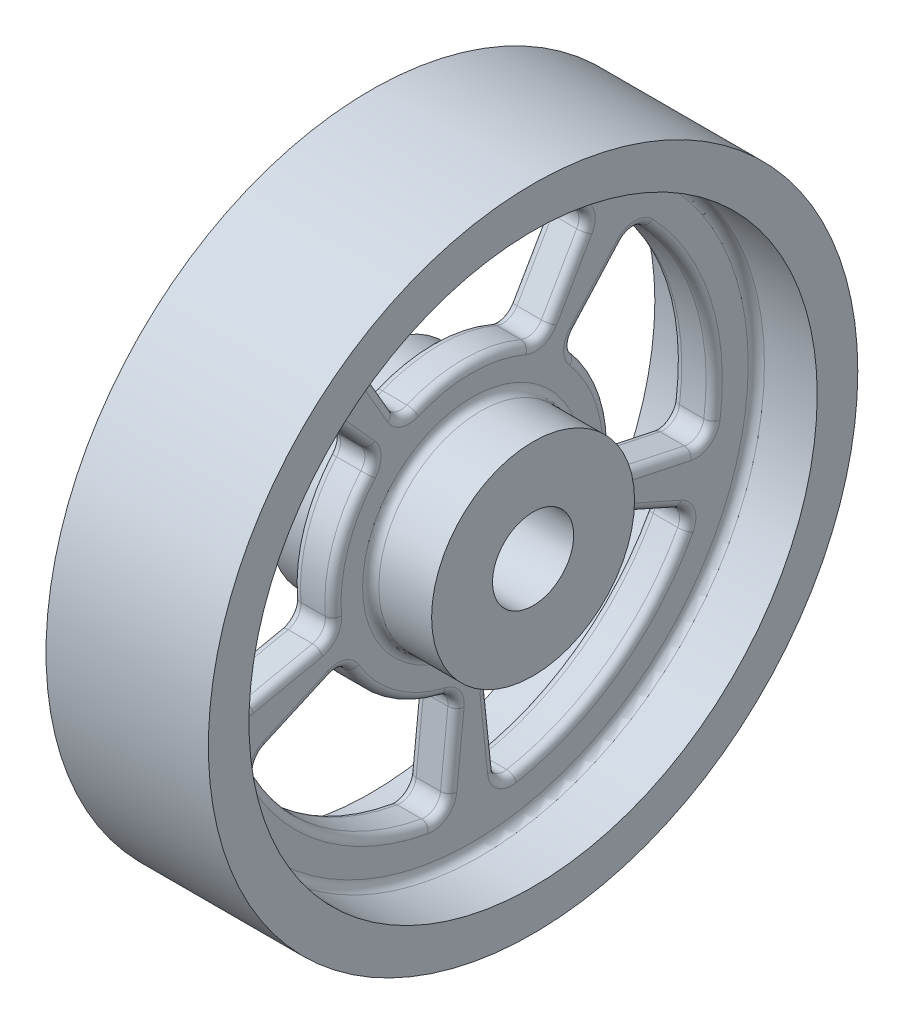
from build123d import *

# Parameters (mm, degrees)
CUT_EXTRUDE1_DEPTH       = 13.5
FILLET1_R                = 2
CIRPATTERN1_COUNT        = 5
FILLET1_OF_CIRPATTERN1_R = 2
FILLET2_R                = 1


with BuildPart() as part:
    # Sketch1 → Revolve2 (revolve)
    with BuildSketch(Plane.XY):
        Polygon((2.5, 12.5), (10, 12.5), (10, 5), (-10, 5), (-10, 12.5), (-2.5, 12.5), (-2.5, 35), (-10, 35), (-10, 40), (10, 40), (10, 35), (2.5, 35), align=None)
    revolve(axis=Axis((44.438670627, 0, 0), (-1, 0, 0)))

    # Sketch3 → Cut-Extrude1 (cut, through all)
    with BuildSketch(Plane.ZY.offset(2.5)):
        with BuildLine():
            Line((14.922429524, 25.846406108), (8.62117749, 14.932317435))
            ThreePointArc((8.62117749, 14.932317435), (0.009875228, 17.091010663), (-8.585861972, 14.871149162))
            Line((-8.585861972, 14.871149162), (-14.910833645, 25.826321456))
            ThreePointArc((-14.910833645, 25.826321456), (0.003124351, 29.807647944), (14.922429524, 25.846406108))
        make_face()
    cut_extrude1 = extrude(amount=-CUT_EXTRUDE1_DEPTH, mode=Mode.SUBTRACT)

    # Fillet1
    fillet1_edges = [part.edges().sort_by_distance(p)[0] for p in [
        (0, 14.932317435, 8.62117749),
        (0, 14.871149162, -8.585861972),
        (0, 25.826321456, -14.910833645),
        (0, 25.846406108, 14.922429524),
    ]]
    fillet(fillet1_edges, radius=FILLET1_R)

    # CirPattern1: Cut-Extrude1 ×5 about axis
    cirpattern1_axis = Axis((0, 0, 0), (1, 0, 0))
    for i in range(1, CIRPATTERN1_COUNT):
        add(cut_extrude1.rotate(cirpattern1_axis, i * 360 / CIRPATTERN1_COUNT), mode=Mode.SUBTRACT)

    # Fillet1 of CirPattern1
    fillet1_of_cirpattern1_edges = [part.edges().sort_by_distance(p)[0] for p in [
        (0, -3.584887178, 16.865568156),
        (0, 12.761077793, 11.490126055),
        (0, 22.161817733, 19.954590316),
        (0, -6.205095107, 29.192677272),
        (0, -17.147899556, 1.802316869),
        (0, -6.984369353, 15.687150409),
        (0, -12.129564844, 27.243448692),
        (0, -29.681365788, 3.119637253),
        (0, -7.013097584, -15.751675072),
        (0, -17.077655443, -1.794933916),
        (0, -29.658301076, -3.117213054),
        (0, -12.138997782, -27.264635417),
        (0, 12.813566883, -11.537387443),
        (0, -3.570202159, -16.796480576),
        (0, -6.200273269, -29.169992309),
        (0, 22.179052569, -19.970108632),
    ]]
    fillet(fillet1_of_cirpattern1_edges, radius=FILLET1_OF_CIRPATTERN1_R)

    # Fillet2
    fillet2_edges = [part.edges().sort_by_distance(p)[0] for p in [
        (-2.5, -35, 0),
        (-2.5, -12.5, 0),
        (2.5, -12.5, 0),
        (2.5, -35, 0),
        (2.5, 17.381148972, 15.650056829),
        (-2.5, 17.381148972, 15.650056829),
        (2.5, 9.209527855, 28.349257709),
        (-2.5, 9.209527855, 28.349257709),
        (2.5, 5.266341172, 16.259435415),
        (-2.5, 5.266341172, 16.259435415),
        (2.5, -4.870915252, 22.915854557),
        (-2.5, -4.870915252, 22.915854557),
        (-2.5, 21.27983554, 20.020608399),
        (2.5, 21.27983554, 20.020608399),
        (-2.5, 12.820797379, 12.221633008),
        (2.5, 12.820797379, 12.221633008),
        (-2.5, -3.20579446, 17.483994284),
        (2.5, -3.20579446, 17.483994284),
        (-2.5, -5.45131568, 28.726014249),
        (2.5, -5.45131568, 28.726014249),
        (2.5, -9.513018114, 21.366588514),
        (-2.5, -9.513018114, 21.366588514),
        (2.5, -24.115845659, 17.519183889),
        (-2.5, -24.115845659, 17.519183889),
        (2.5, -13.836253082, 10.03302995),
        (-2.5, -13.836253082, 10.03302995),
        (2.5, -23.299468394, 2.448872808),
        (-2.5, -23.299468394, 2.448872808),
        (-2.5, -12.464899259, 26.425034489),
        (2.5, -12.464899259, 26.425034489),
        (-2.5, -7.66161944, 15.969995189),
        (2.5, -7.66161944, 15.969995189),
        (-2.5, -17.618911663, 2.353959652),
        (2.5, -17.618911663, 2.353959652),
        (-2.5, -29.004612225, 3.692317284),
        (2.5, -29.004612225, 3.692317284),
        (2.5, -23.260517502, -2.444778904),
        (-2.5, -23.260517502, -2.444778904),
        (2.5, -24.11394014, -17.521806611),
        (-2.5, -24.11394014, -17.521806611),
        (2.5, -13.817615853, -10.058681895),
        (-2.5, -13.817615853, -10.058681895),
        (2.5, -9.528948135, -21.402367928),
        (-2.5, -9.528948135, -21.402367928),
        (-2.5, -28.983566948, -3.689038931),
        (2.5, -28.983566948, -3.689038931),
        (-2.5, -17.555938602, -2.35163318),
        (2.5, -17.555938602, -2.35163318),
        (-2.5, -7.683291793, -16.02916721),
        (2.5, -7.683291793, -16.02916721),
        (-2.5, -12.474520506, -26.44403667),
        (2.5, -12.474520506, -26.44403667),
        (2.5, -4.862772299, -22.877544972),
        (-2.5, -4.862772299, -22.877544972),
        (2.5, 9.21261105, -28.348255919),
        (-2.5, 9.21261105, -28.348255919),
        (2.5, 5.296496841, -16.249637244),
        (-2.5, 5.296496841, -16.249637244),
        (2.5, 17.41025457, -15.676263627),
        (-2.5, 17.41025457, -15.676263627),
        (-2.5, -5.44793023, -28.704985934),
        (2.5, -5.44793023, -28.704985934),
        (-2.5, -3.18854732, -17.423384424),
        (2.5, -3.18854732, -17.423384424),
        (-2.5, 12.870376189, -12.2605298),
        (2.5, 12.870376189, -12.2605298),
        (-2.5, 21.294934559, -20.035630746),
        (2.5, 21.294934559, -20.035630746),
        (2.5, 20.255158942, -11.694321468),
        (-2.5, 20.255158942, -11.694321468),
        (2.5, 29.807646894, 0.001620932),
        (-2.5, 29.807646894, 0.001620932),
        (2.5, 17.091030923, 0.015853774),
        (-2.5, 17.091030923, 0.015853774),
        (2.5, 20.289077212, 11.71390419),
        (-2.5, 20.289077212, 11.71390419),
        (-2.5, 25.616560898, -14.051618023),
        (2.5, 25.616560898, -14.051618023),
        (-2.5, 15.585307983, -8.416610593),
        (2.5, 15.585307983, -8.416610593),
        (-2.5, 15.637621726, 8.451743074),
        (2.5, 15.637621726, 8.451743074),
        (-2.5, 25.635513852, 14.061335883),
        (2.5, 25.635513852, 14.061335883),
    ]]
    fillet(fillet2_edges, radius=FILLET2_R)


solid = part.part
